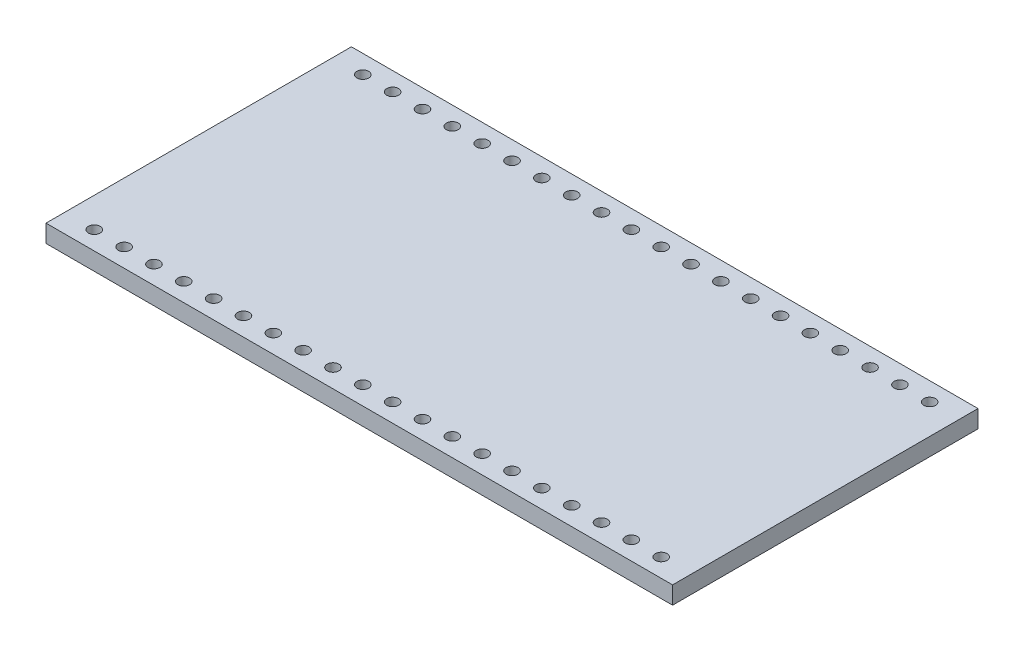
from build123d import *

# Parameters (mm, degrees)
SKETCH1_W           = 53.34
SKETCH1_H           = 26
BOSS_EXTRUDE1_DEPTH = 1.5
SKETCH2_R           = 0.5
CUT_EXTRUDE1_DEPTH  = 1.5
LPATTERN1_COUNT     = 20
LPATTERN1_PITCH     = 2.54


with BuildPart() as part:
    # Sketch1 → Boss-Extrude1 (new body)
    with BuildSketch(Plane(origin=(0, 0, 0), x_dir=(1, 0, 0), z_dir=(0, 1, 0))):
        with Locations((26.67, 13)):
            Rectangle(SKETCH1_W, SKETCH1_H)
    extrude(amount=BOSS_EXTRUDE1_DEPTH)

    # Sketch2 → Cut-Extrude1 (cut)
    with BuildSketch(Plane(origin=(0, 1.5, 0), x_dir=(1, 0, 0), z_dir=(0, 1, 0))):
        with Locations((2.54, 1.57)):
            Circle(SKETCH2_R)
        with Locations((2.54, 24.43)):
            Circle(SKETCH2_R)
    cut_extrude1 = extrude(amount=-CUT_EXTRUDE1_DEPTH, mode=Mode.SUBTRACT)

    # LPattern1: Cut-Extrude1 ×20
    with Locations(*[(i * LPATTERN1_PITCH, 0, 0) for i in range(1, LPATTERN1_COUNT)]):
        add(cut_extrude1, mode=Mode.SUBTRACT)


solid = part.part
